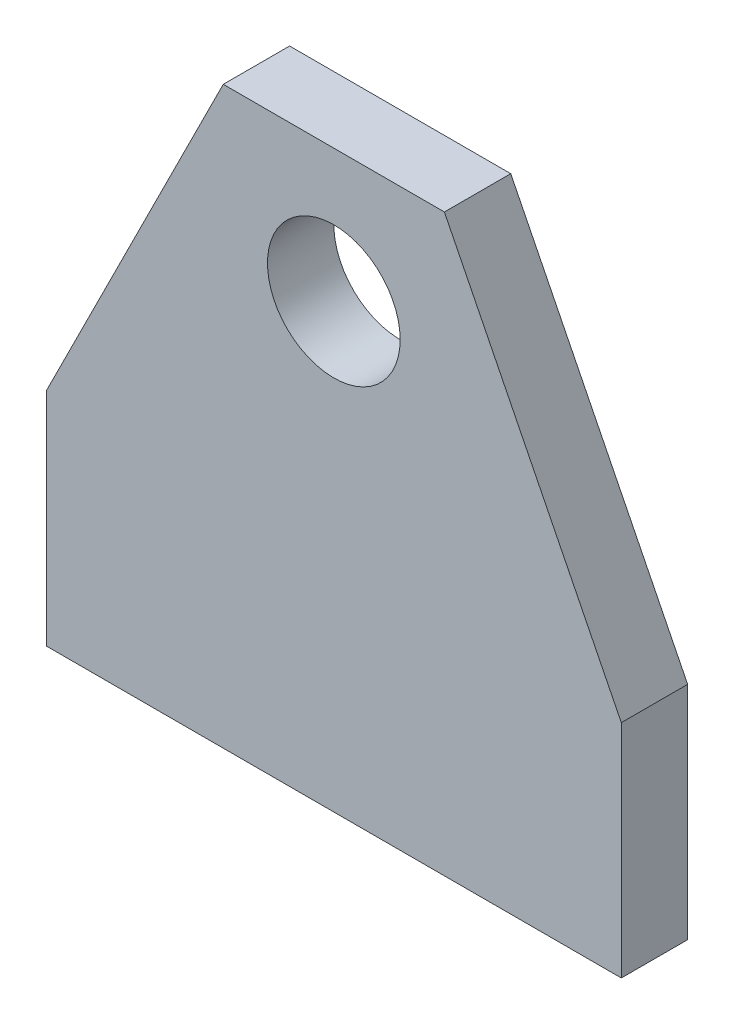
from build123d import *

# Parameters (mm, degrees)
SKETCH1_R          = 9.525
BASE_EXTRUDE_DEPTH = 9.525


with BuildPart() as part:
    # Sketch1 → Base-Extrude (new body)
    with BuildSketch(Plane.XY):
        Polygon((-15.875, 82.55), (15.875, 82.55), (41.275, 31.75), (41.275, 0), (-41.275, 0), (-41.275, 31.75), align=None)
        with Locations((0, 63.5)):
            Circle(SKETCH1_R, mode=Mode.SUBTRACT)
    extrude(amount=BASE_EXTRUDE_DEPTH)


solid = part.part
